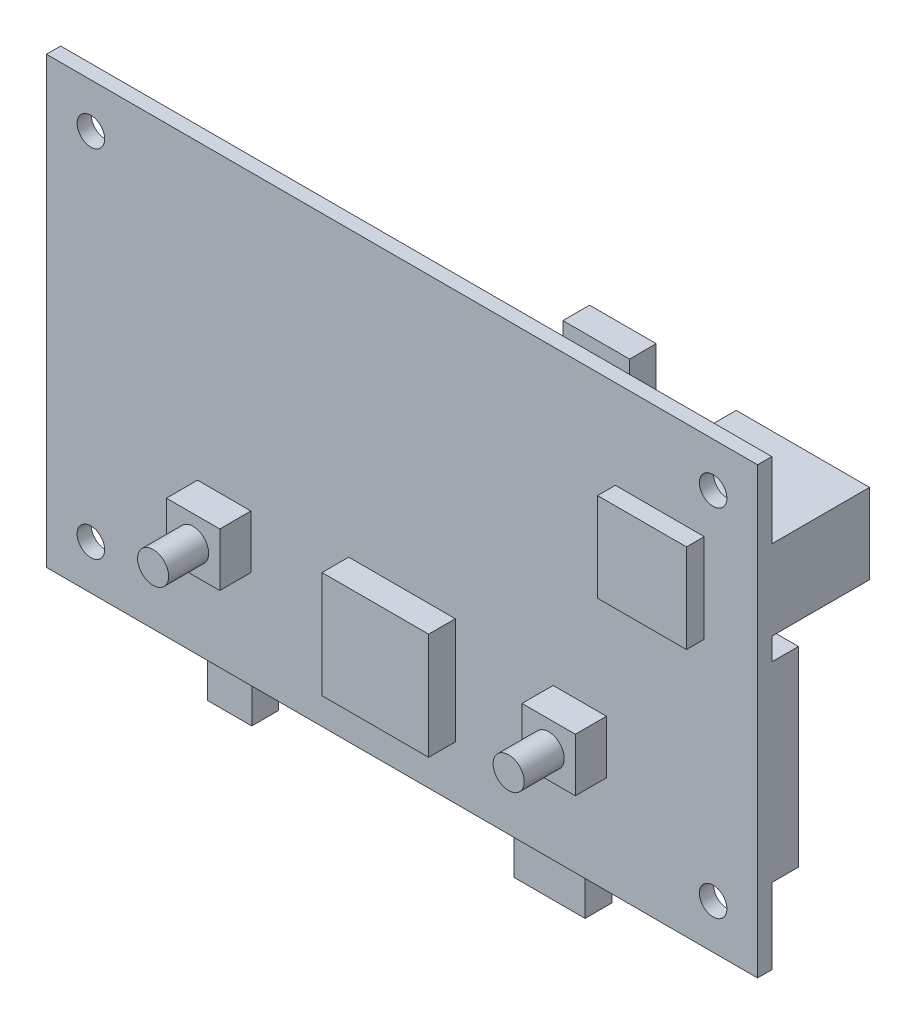
from build123d import *

# Parameters (mm, degrees)
SKETCH_1_W          = 80
SKETCH_1_H          = 50
EXTRUDE_1_DEPTH     = 1.6
SKETCH_2_R          = 1.55
CUT_EXTRUDE_1_DEPTH = 2.6
SKETCH_3_W          = 6
SKETCH_3_H          = 6
EXTRUDE_2_DEPTH     = 3.5
SKETCH_4_R          = 1.75
EXTRUDE_3_DEPTH     = 4.5
SKETCH_5_W          = 12
SKETCH_5_H          = 12
EXTRUDE_4_DEPTH     = 3
SKETCH_6_W          = 10
SKETCH_6_H          = 10
EXTRUDE_5_DEPTH     = 2
SKETCH_7_W          = 16
SKETCH_7_H          = 18
SKETCH_7_W_2        = 3
SKETCH_7_H_2        = 4
SKETCH_7_W_3        = 5
SKETCH_7_H_3        = 10.5
SKETCH_7_W_4        = 8
SKETCH_7_W_5        = 10.5
SKETCH_7_H_4        = 21.5
SKETCH_7_W_6        = 7.5
SKETCH_7_H_5        = 7
SKETCH_7_W_7        = 9
SKETCH_7_H_6        = 5
SKETCH_7_W_8        = 4
SKETCH_7_H_7        = 3
EXTRUDE_6_DEPTH     = 3
SKETCH_8_W          = 6.5
SKETCH_8_H          = 8
EXTRUDE_7_DEPTH     = 5
SKETCH_9_W          = 15
SKETCH_9_H          = 9
EXTRUDE_8_DEPTH     = 11


with BuildPart() as part:
    # ｽｹｯﾁ1 → ﾎﾞｽ - 押し出し1 (new body)
    with BuildSketch(Plane.XY):
        with Locations((40, 25)):
            Rectangle(SKETCH_1_W, SKETCH_1_H)
    extrude(amount=EXTRUDE_1_DEPTH)

    # ｽｹｯﾁ2 → ｶｯﾄ - 押し出し1 (cut, through all)
    with BuildSketch(Plane.XY.offset(1.6)):
        with Locations((75, 45)):
            Circle(SKETCH_2_R)
        with Locations((75, 5)):
            Circle(SKETCH_2_R)
        with Locations((5, 5)):
            Circle(SKETCH_2_R)
        with Locations((5, 45)):
            Circle(SKETCH_2_R)
    extrude(amount=-CUT_EXTRUDE_1_DEPTH, mode=Mode.SUBTRACT)

    # ｽｹｯﾁ3 → ﾎﾞｽ - 押し出し2 (add)
    with BuildSketch(Plane.XY.offset(1.6)):
        with Locations((60, 14)):
            Rectangle(SKETCH_3_W, SKETCH_3_H)
        with Locations((20, 14)):
            Rectangle(SKETCH_3_W, SKETCH_3_H)
    extrude(amount=EXTRUDE_2_DEPTH)

    # ｽｹｯﾁ4 → ﾎﾞｽ - 押し出し3 (add)
    with BuildSketch(Plane.XY.offset(5.1)):
        with Locations((20, 14)):
            Circle(SKETCH_4_R)
        with Locations((60, 14)):
            Circle(SKETCH_4_R)
    extrude(amount=EXTRUDE_3_DEPTH)

    # ｽｹｯﾁ5 → ﾎﾞｽ - 押し出し4 (add)
    with BuildSketch(Plane.XY.offset(1.6)):
        with Locations((40, 12)):
            Rectangle(SKETCH_5_W, SKETCH_5_H)
    extrude(amount=EXTRUDE_4_DEPTH)

    # ｽｹｯﾁ6 → ﾎﾞｽ - 押し出し5 (add)
    with BuildSketch(Plane.XY.offset(1.6)):
        with Locations((69, 35)):
            Rectangle(SKETCH_6_W, SKETCH_6_H)
    extrude(amount=EXTRUDE_5_DEPTH)

    # ｽｹｯﾁ7 → ﾎﾞｽ - 押し出し6 (add)
    with BuildSketch(Plane(origin=(0, 0, 0), x_dir=(-1, 0, 0), z_dir=(0, 0, -1))):
        with Locations((-21, 34)):
            Rectangle(SKETCH_7_W, SKETCH_7_H)
        with Locations((-5, 27)):
            Rectangle(SKETCH_7_W_2, SKETCH_7_H_2)
        with Locations((-19, -0.25)):
            Rectangle(SKETCH_7_W_3, SKETCH_7_H_3)
        with Locations((-55, -0.25)):
            Rectangle(SKETCH_7_W_4, SKETCH_7_H_3)
        with Locations((-74.75, 19.25)):
            Rectangle(SKETCH_7_W_5, SKETCH_7_H_4)
        with Locations((-60.25, 48)):
            Rectangle(SKETCH_7_W_6, SKETCH_7_H_5)
        with Locations((-47.7, 42)):
            Rectangle(SKETCH_7_W_7, SKETCH_7_H_6)
        with Locations((-40, 39.5)):
            Rectangle(SKETCH_7_W_8, SKETCH_7_H_7)
        with Locations((-61, 27)):
            Rectangle(SKETCH_7_W_3, SKETCH_7_H_2)
    extrude(amount=EXTRUDE_6_DEPTH)

    # ｽｹｯﾁ8 → ﾎﾞｽ - 押し出し7 (add)
    with BuildSketch(Plane(origin=(0, 0, 0), x_dir=(-1, 0, 0), z_dir=(0, 0, -1))):
        with Locations((-39.85, 30.5)):
            Rectangle(SKETCH_8_W, SKETCH_8_H)
    extrude(amount=EXTRUDE_7_DEPTH)

    # ｽｹｯﾁ9 → ﾎﾞｽ - 押し出し8 (add)
    with BuildSketch(Plane(origin=(0, 0, 0), x_dir=(-1, 0, 0), z_dir=(0, 0, -1))):
        with Locations((-72.5, 37)):
            Rectangle(SKETCH_9_W, SKETCH_9_H)
    extrude(amount=EXTRUDE_8_DEPTH)


solid = part.part
